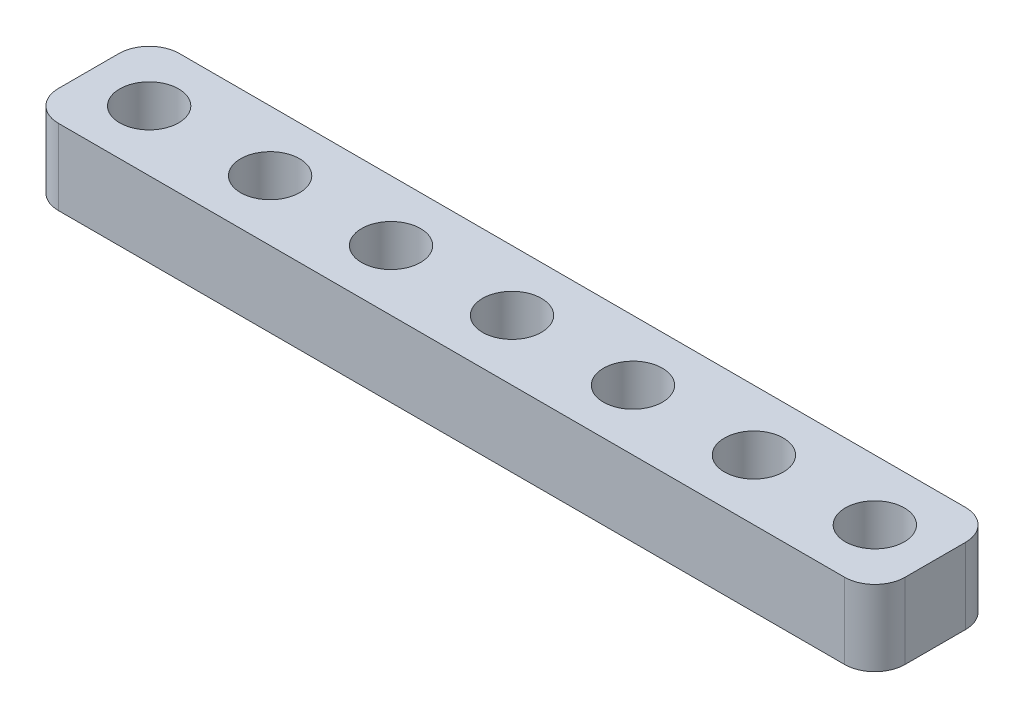
from build123d import *

# Parameters (mm, degrees)
BOSS_EXTRUDE1_DEPTH = 5
SKETCH2_R           = 1.95
CUT_EXTRUDE1_DEPTH  = 6


with BuildPart() as part:
    # Sketch1 → Boss-Extrude1 (new body)
    with BuildSketch(Plane(origin=(0, 0, 0), x_dir=(1, 0, 0), z_dir=(0, 1, 0))):
        with BuildLine():
            Line((2, 0), (54, 0))
            ThreePointArc((54, 0), (55.414213562, -0.585786438), (56, -2))
            Line((56, -2), (56, -6))
            ThreePointArc((56, -6), (55.414213562, -7.414213562), (54, -8))
            Line((54, -8), (2, -8))
            ThreePointArc((2, -8), (0.585786438, -7.414213562), (0, -6))
            Line((0, -6), (0, -2))
            ThreePointArc((0, -2), (0.585786438, -0.585786438), (2, 0))
        make_face()
    extrude(amount=BOSS_EXTRUDE1_DEPTH)

    # Sketch2 → Cut-Extrude1 (cut, through all)
    with BuildSketch(Plane(origin=(0, 5, 0), x_dir=(1, 0, 0), z_dir=(0, 1, 0))):
        with Locations((52, -4)):
            Circle(SKETCH2_R)
        with Locations((44, -4)):
            Circle(SKETCH2_R)
        with Locations((-12, -4)):
            Circle(SKETCH2_R)
        with Locations((-4, -4)):
            Circle(SKETCH2_R)
        with Locations((4, -4)):
            Circle(SKETCH2_R)
        with Locations((12, -4)):
            Circle(SKETCH2_R)
        with Locations((20, -4)):
            Circle(SKETCH2_R)
        with Locations((28, -4)):
            Circle(SKETCH2_R)
        with Locations((36, -4)):
            Circle(SKETCH2_R)
    extrude(amount=-CUT_EXTRUDE1_DEPTH, mode=Mode.SUBTRACT)


solid = part.part
